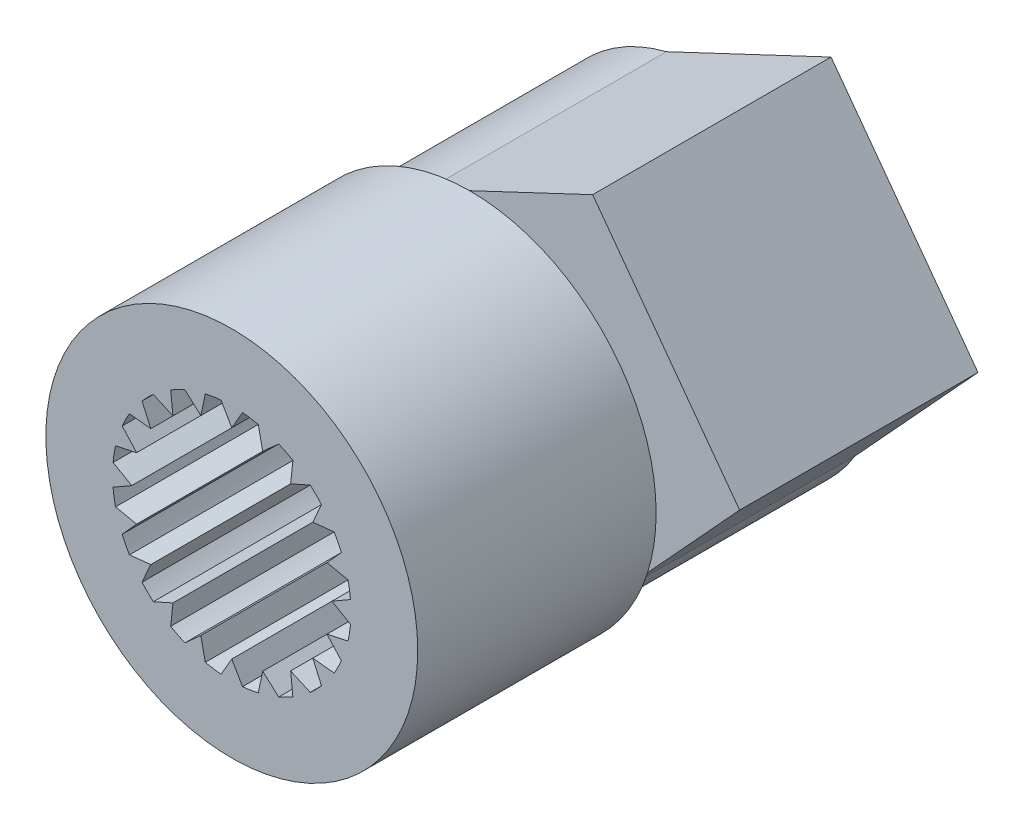
from build123d import *

# Parameters (mm, degrees)
SKETCH3_R           = 3.9
BOSS_EXTRUDE1_DEPTH = 5
SKETCH5_R           = 3.6
BOSS_EXTRUDE2_DEPTH = 5
BOSS_EXTRUDE3_DEPTH = 5
SKETCH7_R           = 1.25
CUT_EXTRUDE1_DEPTH  = 11


with BuildPart() as part:
    # Sketch3 → Boss-Extrude1 (new body)
    with BuildSketch(Plane.XY):
        with Locations((10, 0)):
            Circle(SKETCH3_R)
        with BuildLine():
            Line((10, 2.1), (9.774921544, 2.489847322))
            ThreePointArc((9.774921544, 2.489847322), (9.608913837, 2.469220851), (9.444657197, 2.437538589))
            Line((9.444657197, 2.437538589), (9.351064312, 1.997218684))
            Line((9.351064312, 1.997218684), (9.016532531, 2.298432452))
            ThreePointArc((9.016532531, 2.298432452), (8.865023751, 2.22751631), (8.71859676, 2.146626594))
            Line((8.71859676, 2.146626594), (8.76565097, 1.698935688))
            Line((8.76565097, 1.698935688), (8.354412167, 1.882031))
            ThreePointArc((8.354412167, 1.882031), (8.232233047, 1.767766953), (8.117969, 1.645587833))
            Line((8.117969, 1.645587833), (8.301064312, 1.23434903))
            Line((8.301064312, 1.23434903), (7.853373406, 1.28140324))
            ThreePointArc((7.853373406, 1.28140324), (7.77248369, 1.134976249), (7.701567548, 0.983467469))
            Line((7.701567548, 0.983467469), (8.002781316, 0.648935688))
            Line((8.002781316, 0.648935688), (7.562461411, 0.555342803))
            ThreePointArc((7.562461411, 0.555342803), (7.530779149, 0.391086163), (7.510152678, 0.225078456))
            Line((7.510152678, 0.225078456), (7.9, 0))
            Line((7.9, 0), (7.510152678, -0.225078456))
            ThreePointArc((7.510152678, -0.225078456), (7.530779149, -0.391086163), (7.562461411, -0.555342803))
            Line((7.562461411, -0.555342803), (8.002781316, -0.648935688))
            Line((8.002781316, -0.648935688), (7.701567548, -0.983467469))
            ThreePointArc((7.701567548, -0.983467469), (7.77248369, -1.134976249), (7.853373406, -1.28140324))
            Line((7.853373406, -1.28140324), (8.301064312, -1.23434903))
            Line((8.301064312, -1.23434903), (8.117969, -1.645587833))
            ThreePointArc((8.117969, -1.645587833), (8.232233047, -1.767766953), (8.354412167, -1.882031))
            Line((8.354412167, -1.882031), (8.76565097, -1.698935688))
            Line((8.76565097, -1.698935688), (8.71859676, -2.146626594))
            ThreePointArc((8.71859676, -2.146626594), (8.865023751, -2.22751631), (9.016532531, -2.298432452))
            Line((9.016532531, -2.298432452), (9.351064312, -1.997218684))
            Line((9.351064312, -1.997218684), (9.444657197, -2.437538589))
            ThreePointArc((9.444657197, -2.437538589), (9.608913837, -2.469220851), (9.774921544, -2.489847322))
            Line((9.774921544, -2.489847322), (10, -2.1))
            Line((10, -2.1), (10.225078456, -2.489847322))
            ThreePointArc((10.225078456, -2.489847322), (10.391086163, -2.469220851), (10.555342803, -2.437538589))
            Line((10.555342803, -2.437538589), (10.648935688, -1.997218684))
            Line((10.648935688, -1.997218684), (10.983467469, -2.298432452))
            ThreePointArc((10.983467469, -2.298432452), (11.134976249, -2.22751631), (11.28140324, -2.146626594))
            Line((11.28140324, -2.146626594), (11.23434903, -1.698935688))
            Line((11.23434903, -1.698935688), (11.645587833, -1.882031))
            ThreePointArc((11.645587833, -1.882031), (11.767766953, -1.767766953), (11.882031, -1.645587833))
            Line((11.882031, -1.645587833), (11.698935688, -1.23434903))
            Line((11.698935688, -1.23434903), (12.146626594, -1.28140324))
            ThreePointArc((12.146626594, -1.28140324), (12.22751631, -1.134976249), (12.298432452, -0.983467469))
            Line((12.298432452, -0.983467469), (11.997218684, -0.648935688))
            Line((11.997218684, -0.648935688), (12.437538589, -0.555342803))
            ThreePointArc((12.437538589, -0.555342803), (12.469220851, -0.391086163), (12.489847322, -0.225078456))
            Line((12.489847322, -0.225078456), (12.1, 0))
            Line((12.1, 0), (12.489847322, 0.225078456))
            ThreePointArc((12.489847322, 0.225078456), (12.469220851, 0.391086163), (12.437538589, 0.555342803))
            Line((12.437538589, 0.555342803), (11.997218684, 0.648935688))
            Line((11.997218684, 0.648935688), (12.298432452, 0.983467469))
            ThreePointArc((12.298432452, 0.983467469), (12.22751631, 1.134976249), (12.146626594, 1.28140324))
            Line((12.146626594, 1.28140324), (11.698935688, 1.23434903))
            Line((11.698935688, 1.23434903), (11.882031, 1.645587833))
            ThreePointArc((11.882031, 1.645587833), (11.767766953, 1.767766953), (11.645587833, 1.882031))
            Line((11.645587833, 1.882031), (11.23434903, 1.698935688))
            Line((11.23434903, 1.698935688), (11.28140324, 2.146626594))
            ThreePointArc((11.28140324, 2.146626594), (11.134976249, 2.22751631), (10.983467469, 2.298432452))
            Line((10.983467469, 2.298432452), (10.648935688, 1.997218684))
            Line((10.648935688, 1.997218684), (10.555342803, 2.437538589))
            ThreePointArc((10.555342803, 2.437538589), (10.391086163, 2.469220851), (10.225078456, 2.489847322))
            Line((10.225078456, 2.489847322), (10, 2.1))
        make_face(mode=Mode.SUBTRACT)
    extrude(amount=-BOSS_EXTRUDE1_DEPTH)

    # Sketch5 → Boss-Extrude2 (add)
    with BuildSketch(Plane(origin=(0, 0, -5), x_dir=(-1, 0, 0), z_dir=(0, 0, -1))):
        with Locations((-10, 0)):
            Circle(SKETCH5_R)
    extrude(amount=BOSS_EXTRUDE2_DEPTH)

    # Sketch6 → Boss-Extrude3 (add)
    with BuildSketch(Plane(origin=(0, 0, -10), x_dir=(-1, 0, 0), z_dir=(0, 0, -1))):
        with BuildLine():
            ThreePointArc((-13.070257041, -1.879766396), (-12.89955723, 2.133674734), (-9.118539931, 3.49041948))
            Line((-9.118539931, 3.49041948), (-12.569087005, 5.118573235))
            Line((-12.569087005, 5.118573235), (-15.65106162, 0.930323902))
            Line((-15.65106162, 0.930323902), (-13.070257041, -1.879766396))
        make_face()
    extrude(amount=-BOSS_EXTRUDE3_DEPTH)

    # Sketch7 → Cut-Extrude1 (cut, through all)
    with BuildSketch(Plane(origin=(0, 0, -10), x_dir=(-1, 0, 0), z_dir=(0, 0, -1))):
        with Locations((-10, 0)):
            Circle(SKETCH7_R)
    extrude(amount=-CUT_EXTRUDE1_DEPTH, mode=Mode.SUBTRACT)


solid = part.part
